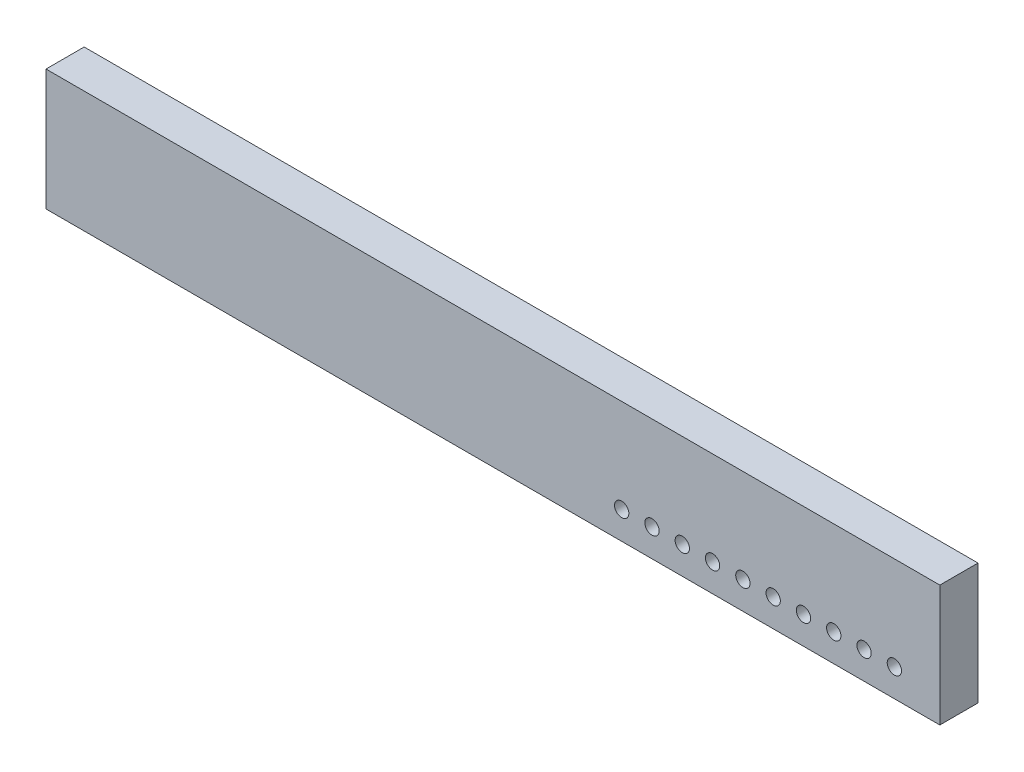
from build123d import *

# Parameters (mm, degrees)
SKETCH1_W           = 37.465
SKETCH1_H           = 5.08
BOSS_EXTRUDE1_DEPTH = 1.6
SKETCH2_R           = 0.3
CUT_EXTRUDE3_DEPTH  = 2.6


with BuildPart() as part:
    # Sketch1 → Boss-Extrude1 (new body)
    with BuildSketch(Plane.XY):
        Rectangle(SKETCH1_W, SKETCH1_H)
    extrude(amount=BOSS_EXTRUDE1_DEPTH)

    # Sketch2 → Cut-Extrude3 (cut, through all)
    with BuildSketch(Plane.XY.offset(1.6)):
        with Locations((5.3975, -1.38)):
            Circle(SKETCH2_R)
        with Locations((6.6675, -1.38)):
            Circle(SKETCH2_R)
        with Locations((7.9375, -1.38)):
            Circle(SKETCH2_R)
        with Locations((9.2075, -1.38)):
            Circle(SKETCH2_R)
        with Locations((10.4775, -1.38)):
            Circle(SKETCH2_R)
        with Locations((11.7475, -1.38)):
            Circle(SKETCH2_R)
        with Locations((13.0175, -1.38)):
            Circle(SKETCH2_R)
        with Locations((14.2875, -1.38)):
            Circle(SKETCH2_R)
        with Locations((15.5575, -1.38)):
            Circle(SKETCH2_R)
        with Locations((16.8275, -1.38)):
            Circle(SKETCH2_R)
    extrude(amount=-CUT_EXTRUDE3_DEPTH, mode=Mode.SUBTRACT)


solid = part.part
